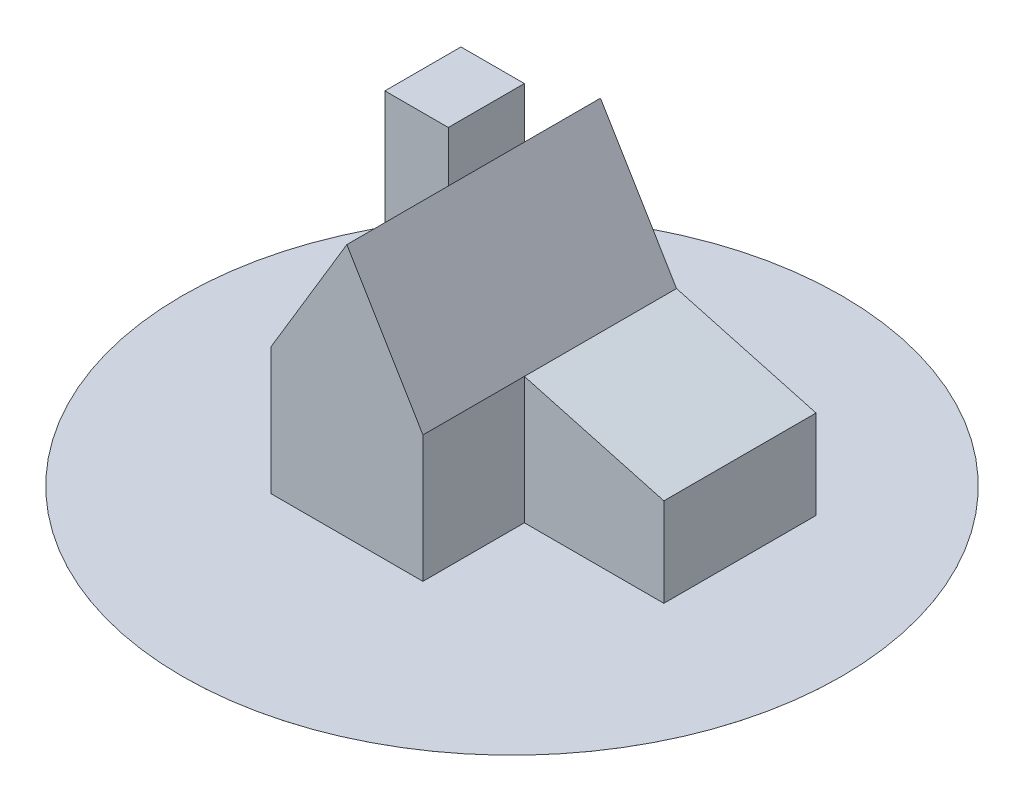
from build123d import *

# Parameters (mm, degrees)
EXTRUDE1_DEPTH = 200
SKETCH2_W      = 110
SKETCH2_H      = 80
EXTRUDE2_DEPTH = 200
SKETCH3_W      = 50
SKETCH3_H      = 60
EXTRUDE3_DEPTH = 180
SKETCH4_R      = 260
EXTRUDE4_DEPTH = 0.01


with BuildPart() as part:
    # Sketch1 → Extrude1 (new body)
    with BuildSketch(Plane.XY):
        Polygon((-60, 200), (0, 100), (110, 70), (110, 0), (0, 0), (-120, 0), (-120, 100), align=None)
    extrude(amount=EXTRUDE1_DEPTH)

    # Sketch2 → Extrude2 (cut)
    with BuildSketch(Plane(origin=(0, 0, 0), x_dir=(1, 0, 0), z_dir=(0, 1, 0))):
        with Locations((55, -160)):
            Rectangle(SKETCH2_W, SKETCH2_H)
    extrude(amount=EXTRUDE2_DEPTH, mode=Mode.SUBTRACT)

    # Sketch3 → Extrude3 (add)
    with BuildSketch(Plane(origin=(0, 0, 0), x_dir=(1, 0, 0), z_dir=(0, 1, 0))):
        with Locations((-145, -30)):
            Rectangle(SKETCH3_W, SKETCH3_H)
    extrude(amount=EXTRUDE3_DEPTH)

    # Sketch4 → Extrude4 (add)
    with BuildSketch(Plane(origin=(0, 0, 0), x_dir=(1, 0, 0), z_dir=(0, 1, 0))):
        with Locations(Location((-30, -99.759965953, 0), (0, 0, 270))):  # turned: the seam where the file's is
            Circle(SKETCH4_R)
    extrude(amount=EXTRUDE4_DEPTH)


solid = part.part
